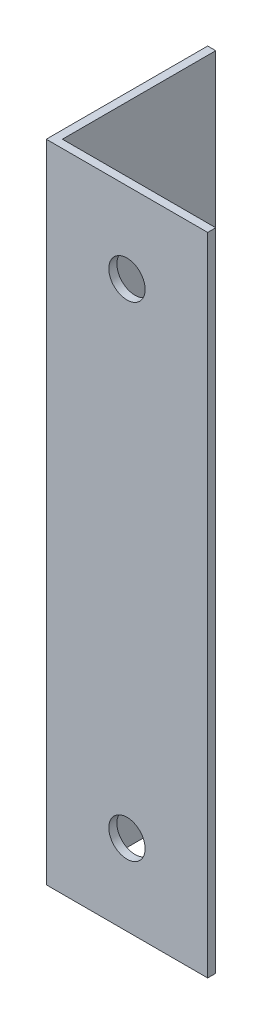
from build123d import *

# Parameters (mm, degrees)
EXTRUDE_1_DEPTH     = 80
SKETCH_2_R          = 2.25
CUT_EXTRUDE_1_DEPTH = 2


with BuildPart() as part:
    # Эскиз1 → Бобышка-Вытянуть1 (new body)
    with BuildSketch(Plane(origin=(0, 0, 0), x_dir=(1, 0, 0), z_dir=(0, 1, 0))):
        Polygon((0, 0), (0, 20), (1, 20), (1, 1), (20, 1), (20, 0), align=None)
    extrude(amount=EXTRUDE_1_DEPTH)

    # Эскиз2 → Вырез-Вытянуть1 (cut, through all)
    with BuildSketch(Plane(origin=(0, 0, -1), x_dir=(-1, 0, 0), z_dir=(0, 0, -1))):
        with Locations((-10, 10)):
            Circle(SKETCH_2_R)
        with Locations((-10, 70)):
            Circle(SKETCH_2_R)
    extrude(amount=-CUT_EXTRUDE_1_DEPTH, mode=Mode.SUBTRACT)


solid = part.part
